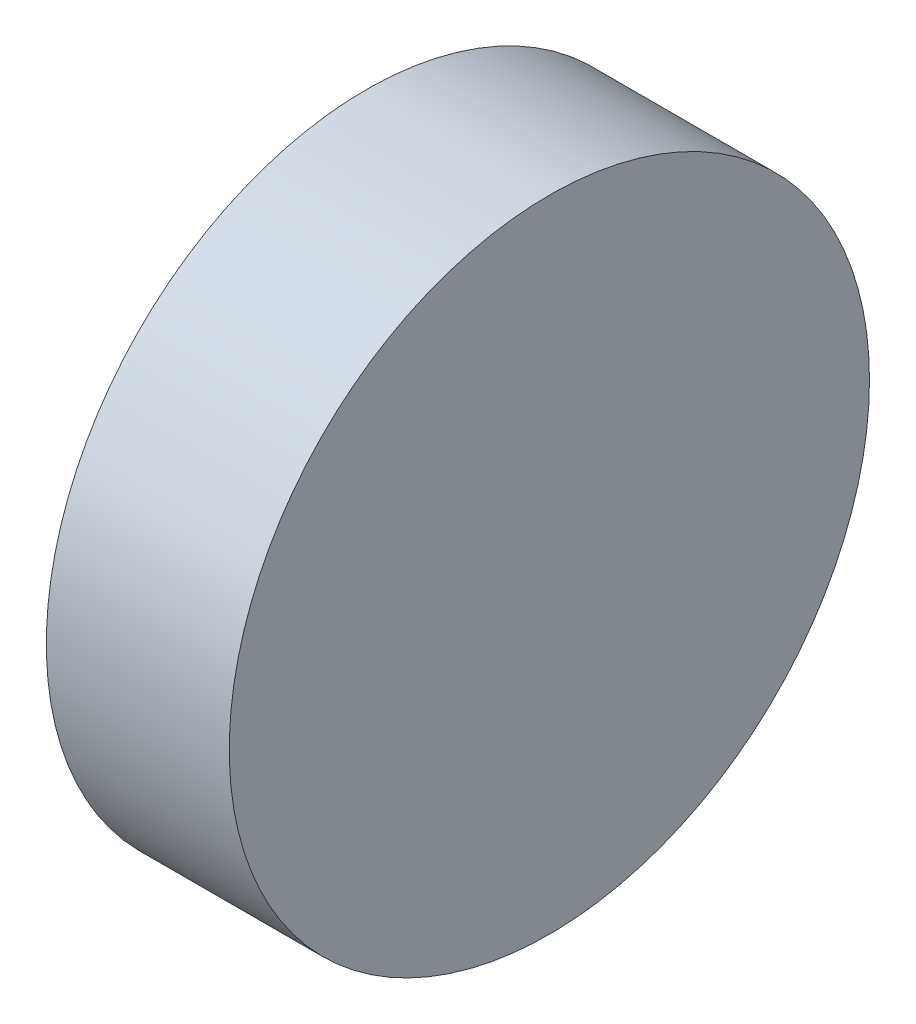
from build123d import *

# Parameters (mm, degrees)
SKETCH1_R           = 1.75
BOSS_EXTRUDE1_DEPTH = 1


with BuildPart() as part:
    # Sketch1 → Boss-Extrude1 (new body)
    with BuildSketch(Plane(origin=(0, 0, 0), x_dir=(0, 0, -1), z_dir=(1, 0, 0))):
        Circle(SKETCH1_R)
    extrude(amount=BOSS_EXTRUDE1_DEPTH)


solid = part.part
